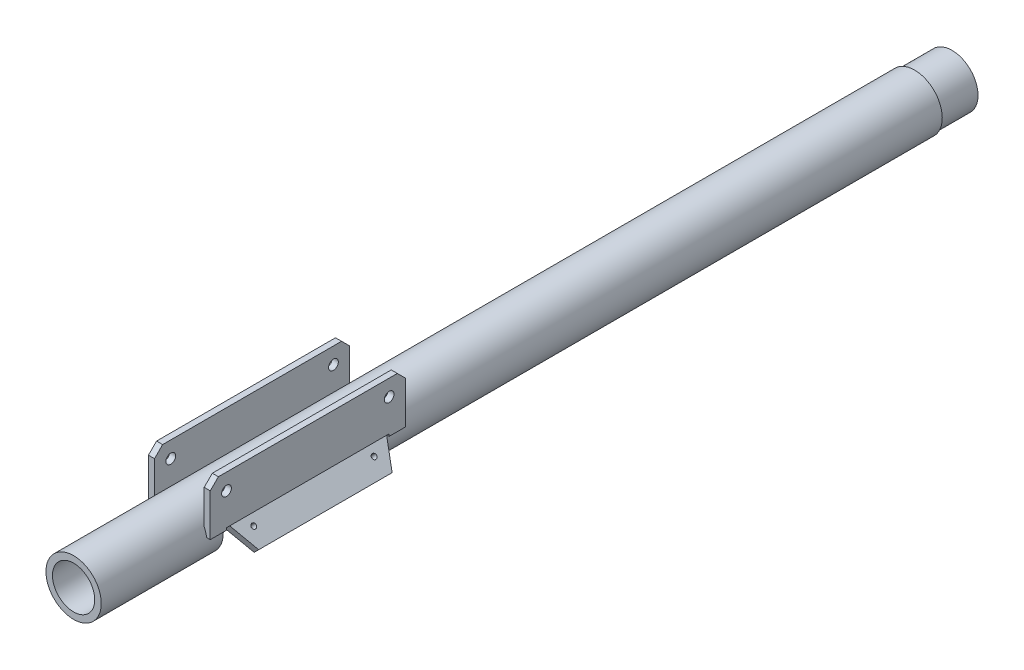
from build123d import *

# Parameters (mm, degrees)
SKETCH1_R                              = 17
OUTER_BARREL_CREATION_DEPTH            = 540
SCREW_INTAKE_EXTRUDE_DEPTH             = 541.534920241
SCREW_INTAKE_EXTRUDE_DEPTH_BACK        = 541.534920241
SKETCH4_W                              = 100
SKETCH4_H                              = 19
PARALLEL_FIN_SIDE_EXTRUSION_DEPTH      = 19
PARALLEL_FIN_SIDE_EXTRUSION_DEPTH_BACK = 19
SKETCH6_W                              = 120
SKETCH6_H                              = 5
SKETCH7_W                              = 3.734431396
SKETCH7_H                              = 120
PARALLEL_FIN_HEIGHT_SIDE_1_DEPTH       = 26
SKETCH8_W                              = 3.734431396
SKETCH8_H                              = 120
PARALLEL_FIN_HEIGHT_SIDE_2_DEPTH       = 26
SKETCH9_R                              = 3
PARALLEL_FIN_DETAILS_DEPTH             = 543.36976702
SKETCH2_R                              = 13
INNER_BARREL_EXTRUSION_DEPTH           = 542.37045004
SKETCH11_W                             = 100
SKETCH11_H                             = 4
BOSS_EXTRUDE6_DEPTH                    = 26
SKETCH12_R                             = 1.5
CUT_EXTRUDE5_DEPTH                     = 4
SKETCH13_R                             = 27.099065824
SKETCH13_R_2                           = 16
CUT_EXTRUDE8_DEPTH                     = 23


with BuildPart() as part:
    # Sketch1 → Outer Barrel Creation (new body)
    with BuildSketch(Plane.XY):
        Circle(SKETCH1_R)
    extrude(amount=-OUTER_BARREL_CREATION_DEPTH)

    # Sketch4 → Screw Intake Extrude (cut, two sides: drawn at the far end of the back side and taken through both)
    with BuildSketch(Plane(origin=(0, 0, 0), x_dir=(0, 0, -1), z_dir=(1, 0, 0)).offset(-SCREW_INTAKE_EXTRUDE_DEPTH_BACK)):
        with Locations((125, -7.5)):
            Rectangle(SKETCH4_W, SKETCH4_H)
    extrude(amount=SCREW_INTAKE_EXTRUDE_DEPTH + SCREW_INTAKE_EXTRUDE_DEPTH_BACK, mode=Mode.SUBTRACT)

    # Sketch6 → Parallel Fin Side Extrusion (add, two sides: drawn at the far end of the back side and taken through both)
    with BuildSketch(Plane(origin=(0, 0, 0), x_dir=(0, 0, -1), z_dir=(1, 0, 0)).offset(-PARALLEL_FIN_SIDE_EXTRUSION_DEPTH_BACK)):
        with Locations((125, 4.980803112)):
            Rectangle(SKETCH6_W, SKETCH6_H)
    extrude(amount=PARALLEL_FIN_SIDE_EXTRUSION_DEPTH + PARALLEL_FIN_SIDE_EXTRUSION_DEPTH_BACK)

    # Sketch7 → Parallel Fin Height Side 1 (add)
    with BuildSketch(Plane(origin=(0, 7.480803112, 0), x_dir=(1, 0, 0), z_dir=(0, 1, 0))):
        with Locations((17.132784302, 125)):
            Rectangle(SKETCH7_W, SKETCH7_H)
    extrude(amount=PARALLEL_FIN_HEIGHT_SIDE_1_DEPTH)

    # Sketch8 → Parallel Fin Height Side 2 (add)
    with BuildSketch(Plane(origin=(0, 7.480803112, 0), x_dir=(1, 0, 0), z_dir=(0, 1, 0))):
        with Locations((-17.132784302, 125)):
            Rectangle(SKETCH8_W, SKETCH8_H)
    extrude(amount=PARALLEL_FIN_HEIGHT_SIDE_2_DEPTH)

    # Sketch9 → Parallel Fin Details (cut, through all)
    with BuildSketch(Plane.ZY.offset(19)):
        with Locations((-175, 23.480803112)):
            Circle(SKETCH9_R)
        with Locations((-75, 23.480803112)):
            Circle(SKETCH9_R)
        Polygon((-180, 33.480803112), (-185, 28.480803112), (-185, 33.480803112), align=None)
        Polygon((-70, 33.480803112), (-65, 28.480803112), (-65, 33.480803112), align=None)
    extrude(amount=-PARALLEL_FIN_DETAILS_DEPTH, mode=Mode.SUBTRACT)

    # Sketch2 → Inner Barrel Extrusion (cut, through all)
    with BuildSketch(Plane.XY):
        Circle(SKETCH2_R)
    extrude(amount=-INNER_BARREL_EXTRUSION_DEPTH, mode=Mode.SUBTRACT)

    # Sketch11 → Boss-Extrude6 (add)
    with BuildSketch(Plane(origin=(0, 0, 0), x_dir=(0, 0, -1), z_dir=(0.7071067811865488, 0.7071067811865464, 0))):
        with Locations((125, 14.15826017)):
            Rectangle(SKETCH11_W, SKETCH11_H)
    boss_extrude6 = extrude(amount=-BOSS_EXTRUDE6_DEPTH)

    # Sketch12 → Cut-Extrude5 (cut)
    with BuildSketch(Plane(origin=(-11.425615339, 11.425615339, 0), x_dir=(0, 0, 1), z_dir=(-0.7071067811865465, 0.7071067811865487, 0))):
        with Locations((-162, -16)):
            Circle(SKETCH12_R)
        with Locations((-88, -16)):
            Circle(SKETCH12_R)
        Polygon((-175, -7.468207578), (-166, -26), (-175, -26), align=None)
        Polygon((-75, -6.46439117), (-75, -26), (-84, -26), align=None)
    cut_extrude5 = extrude(amount=-CUT_EXTRUDE5_DEPTH, mode=Mode.SUBTRACT)

    # Mirror2: Boss-Extrude6, Cut-Extrude5 across plane
    add(boss_extrude6.mirror(Plane(origin=(0, 0, 0), x_dir=(0, 0, 1), z_dir=(1, 0, 0))))
    add(cut_extrude5.mirror(Plane(origin=(0, 0, 0), x_dir=(0, 0, 1), z_dir=(1, 0, 0))), mode=Mode.SUBTRACT)

    # Sketch13 → Cut-Extrude8 (cut)
    with BuildSketch(Plane(origin=(0, 0, -540), x_dir=(-1, 0, 0), z_dir=(0, 0, -1))):
        Circle(SKETCH13_R)
        Circle(SKETCH13_R_2, mode=Mode.SUBTRACT)
    extrude(amount=-CUT_EXTRUDE8_DEPTH, mode=Mode.SUBTRACT)


solid = part.part
